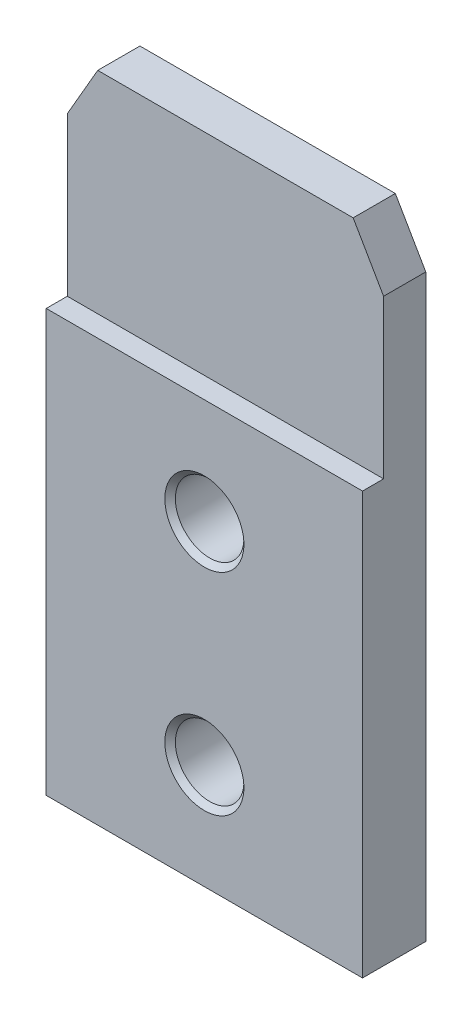
from build123d import *

# Parameters (mm, degrees)
SKETCH_1_W          = 30
SKETCH_1_H          = 60
SKETCH_1_R          = 3.25
EXTRUDE_1_DEPTH     = 6
SKETCH_2_W          = 2
SKETCH_2_H          = 20
CUT_EXTRUDE_1_DEPTH = 31
CHAMFER_2_SIZE      = 5
CHAMFER_2_SIZE2     = 2.886751346
CHAMFER_3_SIZE      = 5
CHAMFER_3_SIZE2     = 2.886751346
CHAMFER_4_SIZE      = 0.5


with BuildPart() as part:
    # Эскиз1 → Бобышка-Вытянуть1 (new body)
    with BuildSketch(Plane.XY):
        Rectangle(SKETCH_1_W, SKETCH_1_H)
        with Locations((0, -20)):
            Circle(SKETCH_1_R, mode=Mode.SUBTRACT)
        Circle(SKETCH_1_R, mode=Mode.SUBTRACT)
    extrude(amount=EXTRUDE_1_DEPTH)

    # Эскиз2 → Вырез-Вытянуть1 (cut, through all)
    with BuildSketch(Plane.ZY.offset(-15)):
        with Locations((5, 20)):
            Rectangle(SKETCH_2_W, SKETCH_2_H)
    extrude(amount=CUT_EXTRUDE_1_DEPTH, mode=Mode.SUBTRACT)

    # Фаска2
    chamfer_2_edges = [part.edges().sort_by_distance(p)[0] for p in [
        (-15, 30, 2),
    ]]
    chamfer_2_side = [part.faces().sort_by_distance(p)[0] for p in [
        (-15, -2.5, 2.75),
    ]]
    chamfer(chamfer_2_edges, length=CHAMFER_2_SIZE, length2=CHAMFER_2_SIZE2, reference=chamfer_2_side[0])

    # Фаска3
    chamfer_3_edges = [part.edges().sort_by_distance(p)[0] for p in [
        (15, 30, 2),
    ]]
    chamfer_3_side = [part.faces().sort_by_distance(p)[0] for p in [
        (15, -2.5, 2.75),
    ]]
    chamfer(chamfer_3_edges, length=CHAMFER_3_SIZE, length2=CHAMFER_3_SIZE2, reference=chamfer_3_side[0])

    # Фаска4
    chamfer_4_edges = [part.edges().sort_by_distance(p)[0] for p in [
        (-3.25, -20, 0),
        (-3.25, -20, 6),
        (-3.25, 0, 0),
        (-3.25, 0, 6),
    ]]
    chamfer(chamfer_4_edges, length=CHAMFER_4_SIZE)


solid = part.part
